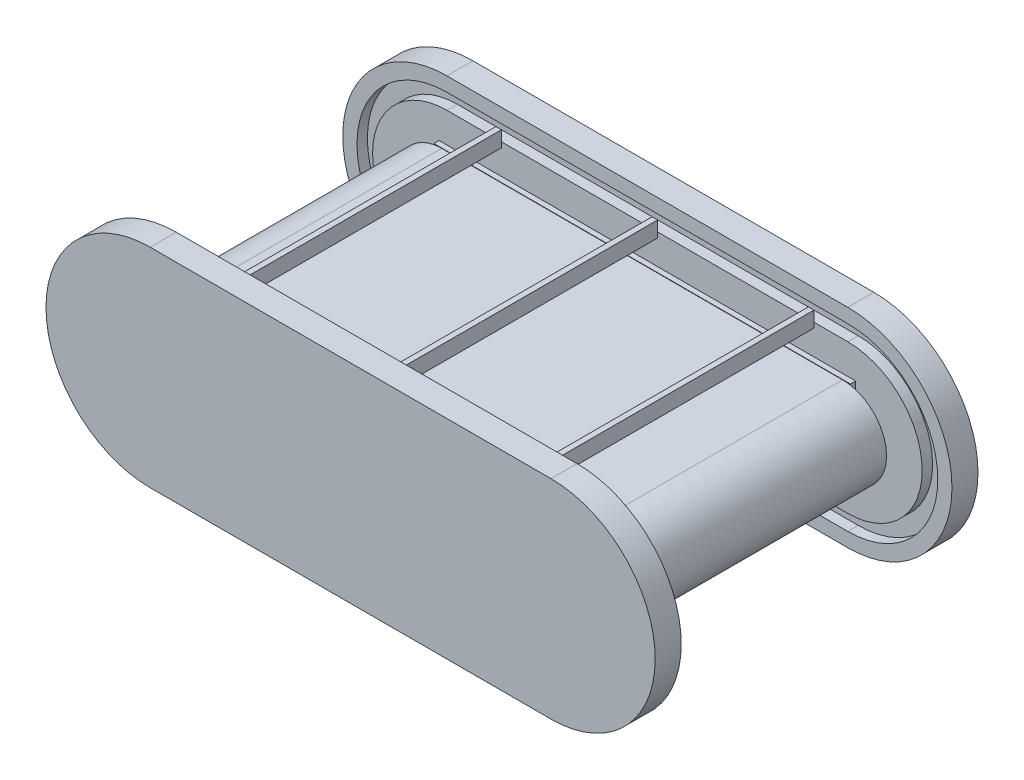
from build123d import *

# Parameters (mm, degrees)
SKETCH3_W           = 800
SKETCH3_H           = 170
SKETCH3_W_2         = 740
SKETCH3_H_2         = 150
BOSS_EXTRUDE1_DEPTH = 10
BOSS_EXTRUDE2_DEPTH = 500
SKETCH5_W           = 800
SKETCH5_H           = 170
SKETCH5_W_2         = 740
SKETCH5_H_2         = 148.57875962
BOSS_EXTRUDE3_DEPTH = 10
SKETCH7_R           = 74.28937981
BOSS_EXTRUDE6_DEPTH = 500
SKETCH6_R           = 10
CUT_EXTRUDE1_DEPTH  = 521
BOSS_EXTRUDE8_DEPTH = 50
CUT_EXTRUDE2_DEPTH  = 20
SKETCH10_W          = 10.613943808
SKETCH10_H          = 30
BOSS_EXTRUDE9_DEPTH = 530


with BuildPart() as part:
    # Sketch3 → Boss-Extrude1 (new body)
    with BuildSketch(Plane.XY):
        with Locations((140, 0)):
            Rectangle(SKETCH3_W, SKETCH3_H)
        with Locations((140, 0)):
            Rectangle(SKETCH3_W_2, SKETCH3_H_2, mode=Mode.SUBTRACT)
    extrude(amount=BOSS_EXTRUDE1_DEPTH)

    # Sketch4 → Boss-Extrude2 (add)
    with BuildSketch(Plane.XY.offset(10)):
        with BuildLine():
            Line((-245, 84.28937981), (525, 84.28937981))
            ThreePointArc((525, 84.28937981), (609.28937981, 0), (525, -84.28937981))
            Line((525, -84.28937981), (-245, -84.28937981))
            ThreePointArc((-245, -84.28937981), (-329.28937981, 0), (-245, 84.28937981))
        make_face()
        with BuildLine():
            Line((-245, 74.28937981), (525, 74.28937981))
            ThreePointArc((525, 74.28937981), (599.28937981, 0), (525, -74.28937981))
            Line((525, -74.28937981), (-245, -74.28937981))
            ThreePointArc((-245, -74.28937981), (-319.28937981, 0), (-245, 74.28937981))
        make_face(mode=Mode.SUBTRACT)
    extrude(amount=BOSS_EXTRUDE2_DEPTH)

    # Sketch5 → Boss-Extrude3 (add)
    with BuildSketch(Plane.XY.offset(510)):
        with Locations((140, 0)):
            Rectangle(SKETCH5_W, SKETCH5_H)
        with Locations((140, 0)):
            Rectangle(SKETCH5_W_2, SKETCH5_H_2, mode=Mode.SUBTRACT)
    extrude(amount=BOSS_EXTRUDE3_DEPTH)

    # Sketch7 → Boss-Extrude6 (add)
    with BuildSketch(Plane.XY.offset(10)):
        with Locations((-245, 0)):
            Circle(SKETCH7_R)
        with Locations((525, 0)):
            Circle(SKETCH7_R)
    extrude(amount=BOSS_EXTRUDE6_DEPTH)

    # Sketch6 → Cut-Extrude1 (cut, through all)
    with BuildSketch(Plane.XY.offset(520)):
        with Locations((-245, 0)):
            Circle(SKETCH6_R)
        with Locations((525, 0)):
            Circle(SKETCH6_R)
    extrude(amount=-CUT_EXTRUDE1_DEPTH, mode=Mode.SUBTRACT)

    # Sketch8 → Boss-Extrude8 (add)
    with BuildSketch(Plane.XY.offset(520)):
        with BuildLine():
            Line((-245, 200), (525, 200))
            ThreePointArc((525, 200), (725, 0), (525, -200))
            Line((525, -200), (-245, -200))
            ThreePointArc((-245, -200), (-445, 0), (-245, 200))
        make_face()
    boss_extrude8 = extrude(amount=BOSS_EXTRUDE8_DEPTH)

    # Sketch9 → Cut-Extrude2 (cut)
    with BuildSketch(Plane(origin=(0, 0, 520), x_dir=(-1, 0, 0), z_dir=(0, 0, -1))):
        with BuildLine():
            Line((-525, 172.743663041), (245, 172.743663041))
            ThreePointArc((245, 172.743663041), (417.743663041, 0), (245, -172.743663041))
            Line((245, -172.743663041), (-525, -172.743663041))
            ThreePointArc((-525, -172.743663041), (-697.743663041, 0), (-525, 172.743663041))
        make_face()
        with BuildLine():
            Line((-525, -142.743663041), (245, -142.743663041))
            ThreePointArc((245, -142.743663041), (387.743663041, 0), (245, 142.743663041))
            Line((245, 142.743663041), (-525, 142.743663041))
            ThreePointArc((-525, 142.743663041), (-667.743663041, 0), (-525, -142.743663041))
        make_face(mode=Mode.SUBTRACT)
    cut_extrude2 = extrude(amount=-CUT_EXTRUDE2_DEPTH, mode=Mode.SUBTRACT)

    # Sketch10 → Boss-Extrude9 (add)
    with BuildSketch(Plane(origin=(0, 0, 540), x_dir=(-1, 0, 0), z_dir=(0, 0, -1))):
        with Locations((135.520291363, 157.743663041)):
            Rectangle(SKETCH10_W, SKETCH10_H)
        with Locations((-164.479708637, 157.743663041)):
            Rectangle(SKETCH10_W, SKETCH10_H)
        with Locations((-464.479708637, 157.743663041)):
            Rectangle(SKETCH10_W, SKETCH10_H)
    extrude(amount=BOSS_EXTRUDE9_DEPTH)

    # Mirror1: Boss-Extrude8, Cut-Extrude2 across plane
    add(boss_extrude8.mirror(Plane(origin=(0, 0, 260), x_dir=(1, 0, 0), z_dir=(0, 0, -1))))
    add(cut_extrude2.mirror(Plane(origin=(0, 0, 260), x_dir=(1, 0, 0), z_dir=(0, 0, -1))), mode=Mode.SUBTRACT)


solid = part.part
